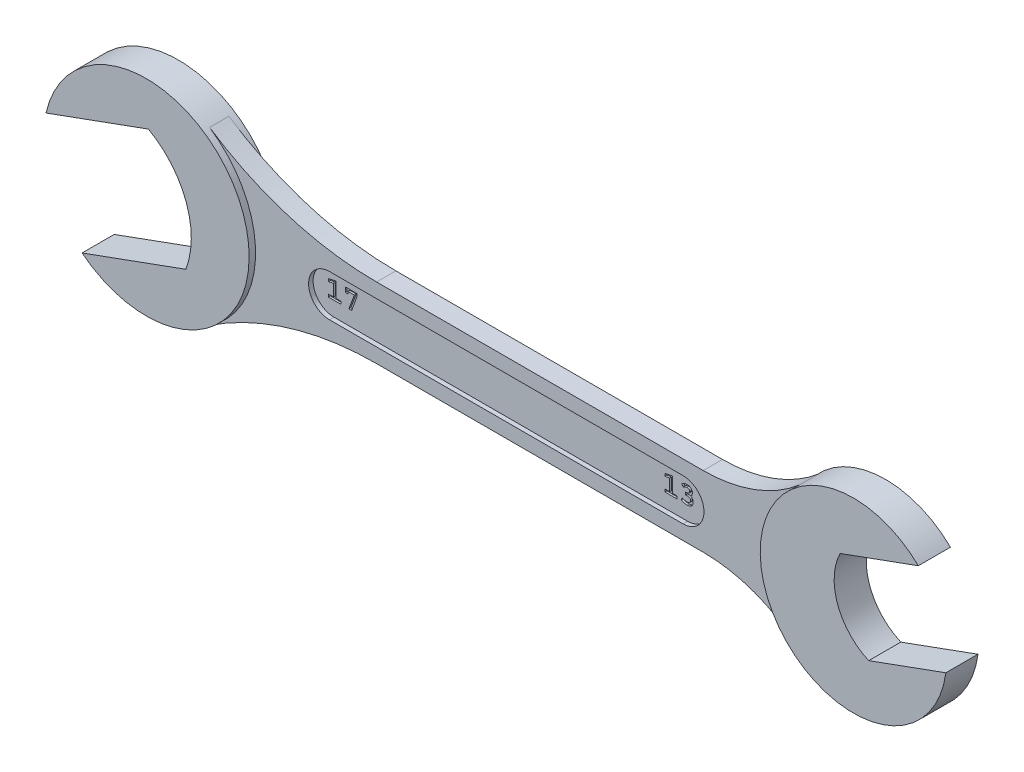
from build123d import *

# Parameters (mm, degrees)
BOSS_EXTRUDE1_DEPTH   = 2.5
BOSS_EXTRUDE1_2_DEPTH = 2.5
BOSS_EXTRUDE2_DEPTH   = 1.5
BOSS_EXTRUDE3_DEPTH   = 0.8
CUT_EXTRUDE1_DEPTH    = 0.3


with BuildPart() as part:
    # Sketch1 → Boss-Extrude1 (new, symmetric)
    with BuildSketch(Plane.XY):
        with BuildLine():
            ThreePointArc((-125.445099671, 11.007112028), (-100.351293752, 28.785221829), (-131.055854145, 27.05598654))
            Line((-131.055854145, 27.05598654), (-115.119096652, 32.856491898))
            ThreePointArc((-115.119096652, 32.856491898), (-109.238886252, 25.951202389), (-109.304754215, 16.881717345))
            Line((-109.304754215, 16.881717345), (-125.445099671, 11.007112028))
        make_face()
    extrude(amount=BOSS_EXTRUDE1_DEPTH, both=True)



with BuildPart() as body_2:
    # Sketch1 → Boss-Extrude1 2 (new, symmetric)
    with BuildSketch(Plane.XY):
        with BuildLine():
            ThreePointArc((4.640921918, 33.912849787), (-19.145316415, 18.727678402), (8.924364925, 21.6375845))
            Line((8.924364925, 21.6375845), (-3.081298781, 17.267880268))
            ThreePointArc((-3.081298781, 17.267880268), (-7.912123909, 22.426759235), (-7.527560645, 29.483884338))
            Line((-7.527560645, 29.483884338), (4.640921918, 33.912849787))
        make_face()
    extrude(amount=BOSS_EXTRUDE1_2_DEPTH, both=True)


with BuildPart() as part_1:
    add(part.part)

    add(body_2.part)  # Boss-Extrude2 merges body 2
    # Sketch1_3 → Boss-Extrude2 (add, symmetric)
    with BuildSketch(Plane.XY):
        with BuildLine():
            Line((-29.827005536, 29.004940525), (-80.630330023, 29.004940525))
            ThreePointArc((-80.630330023, 29.004940525), (-94.198061349, 31.005866461), (-106.610557548, 36.838273859))
            ThreePointArc((-106.610557548, 36.838273859), (-99.454890322, 23.504940525), (-106.610557548, 10.171607192))
            ThreePointArc((-106.610557548, 10.171607192), (-94.198061349, 16.00401459), (-80.630330023, 18.004940525))
            Line((-80.630330023, 18.004940525), (-29.827005536, 18.004940525))
            ThreePointArc((-29.827005536, 18.004940525), (-21.859571821, 16.580853021), (-14.878774872, 12.484940525))
            ThreePointArc((-14.878774872, 12.484940525), (-19.954890322, 23.504940525), (-14.878774872, 34.524940525))
            ThreePointArc((-14.878774872, 34.524940525), (-21.859571821, 30.42902803), (-29.827005536, 29.004940525))
        make_face()
        with BuildLine():
            ThreePointArc((-87.954890322, 20.254940525), (-91.204890322, 23.504940525), (-87.954890322, 26.754940525))
            Line((-87.954890322, 26.754940525), (-32.954890322, 26.754940525))
            ThreePointArc((-32.954890322, 26.754940525), (-29.704890322, 23.504940525), (-32.954890322, 20.254940525))
            Line((-32.954890322, 20.254940525), (-87.954890322, 20.254940525))
        make_face(mode=Mode.SUBTRACT)
    extrude(amount=BOSS_EXTRUDE2_DEPTH, both=True)

    # Sketch1_4 → Boss-Extrude3 (add, symmetric)
    with BuildSketch(Plane.XY):
        with BuildLine():
            Line((-32.954890322, 26.754940525), (-87.954890322, 26.754940525))
            ThreePointArc((-87.954890322, 26.754940525), (-91.204890322, 23.504940525), (-87.954890322, 20.254940525))
            Line((-87.954890322, 20.254940525), (-32.954890322, 20.254940525))
            ThreePointArc((-32.954890322, 20.254940525), (-29.704890322, 23.504940525), (-32.954890322, 26.754940525))
        make_face()
    extrude(amount=BOSS_EXTRUDE3_DEPTH, both=True)

    # Sketch2 → Cut-Extrude1 (cut)
    with BuildSketch(Plane.XY.offset(0.8)):
        Polygon((-86.854638633, 22.528582654), (-86.854638633, 22.93847604), (-87.612258124, 22.93847604), (-87.612258124, 25.278578845), (-88.779771634, 25.0409822), (-88.779771634, 24.633033243), (-88.022152143, 24.785453733), (-88.022152143, 22.93847604), (-88.797703456, 22.93847604), (-88.797703456, 22.528582654), align=None)
        Polygon((-84.351351939, 24.921721521), (-84.351351939, 25.221425911), (-86.195791739, 25.221425911), (-86.195791739, 24.465376532), (-85.78589772, 24.465376532), (-85.78589772, 24.811531892), (-84.786198628, 24.811531892), (-85.646926097, 22.52858202), (-85.19863054, 22.52858202), align=None)
        Polygon((-34.560285317, 22.442112424), (-34.560285317, 22.85200581), (-35.317904807, 22.85200581), (-35.317904807, 25.192108615), (-36.485418317, 24.95451197), (-36.485418317, 24.546563014), (-35.727798827, 24.698983503), (-35.727798827, 22.85200581), (-36.50335014, 22.85200581), (-36.50335014, 22.442112424), align=None)
        with BuildLine():
            add(Edge.make_bspline(
                [(-32.081238757, 23.228178224), (-32.082198696, 23.250674634), (-32.084057511, 23.294236425), (-32.090522202, 23.357487495), (-32.100227275, 23.416622802), (-32.112827156, 23.471857288), (-32.129761905, 23.522600495), (-32.150042199, 23.568986318), (-32.173033426, 23.611600845), (-32.210029943, 23.661363479), (-32.261342008, 23.717830879), (-32.326288197, 23.781991055), (-32.398472874, 23.839339785), (-32.449899329, 23.873230427), (-32.475890855, 23.890359151)],
                knots=[0, 0, 0, 0, 0.997637399, 1.931813618, 2.815349259, 3.651878849, 4.439531487, 5.181711713, 5.893531829, 6.579549641, 7.92326635, 9.271449227, 10.620958872, 12, 12, 12, 12], degree=3))
            add(Edge.make_bspline(
                [(-32.475890855, 23.890359151), (-32.460537871, 23.903523305), (-32.428579298, 23.930925639), (-32.383319762, 23.978385021), (-32.339662701, 24.033383749), (-32.295178265, 24.09396192), (-32.255768604, 24.165171303), (-32.228903795, 24.249510023), (-32.210383469, 24.344879315), (-32.207141642, 24.412573005), (-32.205439048, 24.448125467)],
                knots=[0, 0, 0, 0, 0.755457055, 1.572549691, 2.445674098, 3.378258861, 4.379591996, 5.47048906, 6.671510731, 8, 8, 8, 8], degree=3))
            add(Edge.make_bspline(
                [(-32.205439048, 24.448125467), (-32.206028129, 24.484978023), (-32.207185391, 24.557375489), (-32.228398939, 24.662598727), (-32.265485787, 24.761461874), (-32.302333125, 24.82050909), (-32.320883704, 24.850236067)],
                knots=[0, 0, 0, 0, 1.038347223, 2.039850628, 3.013174174, 4, 4, 4, 4], degree=3))
            add(Edge.make_bspline(
                [(-32.320883704, 24.850236067), (-32.344310243, 24.876736965), (-32.39018372, 24.928630602), (-32.467700767, 24.995853381), (-32.54970191, 25.05263076), (-32.636683909, 25.09914211), (-32.728509332, 25.135081767), (-32.825475752, 25.159563896), (-32.927049279, 25.174246499), (-32.996422622, 25.175286773), (-33.031711475, 25.175815941)],
                knots=[0, 0, 0, 0, 1.047201952, 2.05061425, 3.031524354, 3.997361285, 4.966930277, 5.945809098, 6.955073553, 8, 8, 8, 8], degree=3))
            add(Edge.make_bspline(
                [(-33.031711475, 25.175815941), (-33.070490129, 25.174048713), (-33.14697225, 25.170563255), (-33.259284427, 25.151031326), (-33.36750693, 25.121628853), (-33.505154495, 25.065398362), (-33.671374498, 24.979723173), (-33.797615534, 24.899227918), (-33.861226729, 24.858667419)],
                knots=[0, 0, 0, 0, 0.774711488, 1.527943091, 2.271795288, 3.010338948, 4.493549173, 6, 6, 6, 6], degree=3))
            Line((-33.861226729, 24.858667419), (-33.659213148, 24.541413758))
            add(Edge.make_bspline(
                [(-33.659213148, 24.541413758), (-33.624012242, 24.561187196), (-33.557533942, 24.598530112), (-33.461365372, 24.647018302), (-33.37599501, 24.687096866), (-33.299181729, 24.717858436), (-33.228146212, 24.740672948), (-33.160080142, 24.756428564), (-33.093136107, 24.765295381), (-33.049031313, 24.765714718), (-33.027171516, 24.765922554)],
                knots=[0, 0, 0, 0, 1.427203153, 2.695329442, 3.806731337, 4.760492174, 5.618593777, 6.441812049, 7.227710449, 8, 8, 8, 8], degree=3))
            add(Edge.make_bspline(
                [(-33.027171516, 24.765922554), (-33.003970788, 24.765578384), (-32.957364996, 24.764887011), (-32.888176647, 24.750360857), (-32.820067255, 24.726869178), (-32.765307146, 24.699183699), (-32.724063875, 24.671702672), (-32.696963426, 24.646333857), (-32.673590364, 24.617787014), (-32.653837076, 24.585547894), (-32.638352279, 24.549681189), (-32.626879444, 24.510208121), (-32.61803234, 24.467509906), (-32.616249499, 24.437578884), (-32.615332434, 24.422182848)],
                knots=[0, 0, 0, 0, 1.383119657, 2.778420867, 4.199473821, 5.677800951, 6.429933287, 7.151750679, 7.885821576, 8.627686936, 9.402530253, 10.211378093, 11.079961688, 12, 12, 12, 12], degree=3))
            add(Edge.make_bspline(
                [(-32.615332434, 24.422182848), (-32.617293145, 24.402882754), (-32.621072917, 24.365676882), (-32.633319627, 24.312604504), (-32.651481566, 24.265057332), (-32.674779311, 24.222657197), (-32.704640415, 24.186657499), (-32.7392958, 24.155494821), (-32.780210282, 24.130831335), (-32.840364337, 24.106047057), (-32.917436038, 24.083494625), (-33.00811963, 24.064608848), (-33.095228371, 24.053697891), (-33.151887186, 24.055071749), (-33.179584405, 24.055743349)],
                knots=[0, 0, 0, 0, 0.918499613, 1.770643123, 2.571443264, 3.323536851, 4.051388101, 4.776929623, 5.521734765, 6.301764108, 7.853766344, 9.318126867, 10.688987257, 12, 12, 12, 12], degree=3))
            Line((-33.179584405, 24.055743349), (-33.242298281, 24.055743349))
            Line((-33.242298281, 24.055743349), (-33.242298281, 23.64584933))
            Line((-33.242298281, 23.64584933), (-33.004701636, 23.64584933))
            add(Edge.make_bspline(
                [(-33.004701636, 23.64584933), (-32.98253747, 23.646270776), (-32.935201419, 23.647170861), (-32.860508242, 23.634697016), (-32.778630705, 23.613464762), (-32.706647837, 23.589555753), (-32.649554569, 23.562091905), (-32.609878305, 23.535601679), (-32.576305044, 23.501662935), (-32.548506119, 23.461743568), (-32.525575042, 23.416050358), (-32.507408467, 23.364715462), (-32.495233808, 23.307123859), (-32.491469205, 23.266709828), (-32.48951073, 23.245685059)],
                knots=[0, 0, 0, 0, 1.080573814, 2.30778358, 3.680150362, 5.212613472, 6.001048844, 6.76820704, 7.529605544, 8.317475324, 9.134236718, 10.019046692, 10.969439967, 12, 12, 12, 12], degree=3))
            add(Edge.make_bspline(
                [(-32.48951073, 23.245685059), (-32.490476357, 23.228576793), (-32.492357709, 23.195244379), (-32.500657173, 23.146828248), (-32.514625742, 23.102022617), (-32.531996976, 23.05971864), (-32.554926296, 23.020857004), (-32.582262434, 22.984607635), (-32.615194927, 22.952438789), (-32.663625591, 22.912427051), (-32.732764457, 22.87121141), (-32.824788442, 22.836328489), (-32.925386648, 22.814145664), (-32.99548754, 22.811740476), (-33.031711475, 22.810497619)],
                knots=[0, 0, 0, 0, 0.793019458, 1.545057401, 2.26698385, 2.962258569, 3.657533288, 4.35020938, 5.057980409, 5.783368027, 7.256212158, 8.75815498, 10.324808989, 12, 12, 12, 12], degree=3))
            add(Edge.make_bspline(
                [(-33.031711475, 22.810497619), (-33.057239078, 22.810779179), (-33.10839668, 22.811343428), (-33.184874866, 22.818827862), (-33.26146155, 22.830916936), (-33.325316824, 22.846761081), (-33.379110162, 22.861259605), (-33.423413923, 22.875242096), (-33.472521049, 22.889801603), (-33.525412368, 22.907794813), (-33.583295426, 22.926324431), (-33.645349473, 22.947065115), (-33.711682837, 22.969875733), (-33.757247289, 22.985805689), (-33.780804609, 22.994041651)],
                knots=[0, 0, 0, 0, 1.18470476, 2.374161597, 3.563830137, 4.781037653, 5.426276517, 6.150167203, 6.937514899, 7.80398459, 8.743468701, 9.759104015, 10.84143228, 12, 12, 12, 12], degree=3))
            Line((-33.780804609, 22.994041651), (-33.932699406, 22.645634046))
            add(Edge.make_bspline(
                [(-33.932699406, 22.645634046), (-33.904394378, 22.633641071), (-33.844888771, 22.608428261), (-33.750133449, 22.571829197), (-33.645989159, 22.533101916), (-33.53371177, 22.490895191), (-33.411279749, 22.451944649), (-33.278020005, 22.426325237), (-33.135832069, 22.406250701), (-33.037624909, 22.402525856), (-32.986960456, 22.400604233)],
                knots=[0, 0, 0, 0, 0.749646907, 1.575981332, 2.476906848, 3.459318656, 4.501642132, 5.604907474, 6.764386928, 8, 8, 8, 8], degree=3))
            add(Edge.make_bspline(
                [(-32.986960456, 22.400604233), (-32.963811442, 22.400638791), (-32.916965083, 22.400708725), (-32.84624854, 22.408225504), (-32.774723191, 22.421259194), (-32.702417888, 22.440028858), (-32.629762783, 22.465688037), (-32.556302391, 22.496835797), (-32.482268707, 22.53433625), (-32.407469397, 22.575937486), (-32.335911893, 22.625506221), (-32.273287179, 22.68614563), (-32.218786385, 22.754950085), (-32.173285852, 22.832688485), (-32.136887674, 22.919352817), (-32.109399276, 23.01449695), (-32.089478724, 23.118275432), (-32.084263425, 23.19068267), (-32.081238757, 23.228178224)],
                knots=[0, 0, 0, 0, 0.809124069, 1.637413845, 2.48271312, 3.350107159, 4.246762125, 5.174991567, 6.13863274, 7.147680756, 8.167211206, 9.172513377, 10.184446414, 11.228272943, 12.312367203, 13.463092452, 14.686436477, 16, 16, 16, 16], degree=3))
        make_face()
    extrude(amount=-CUT_EXTRUDE1_DEPTH, mode=Mode.SUBTRACT)


solid = part_1.part
